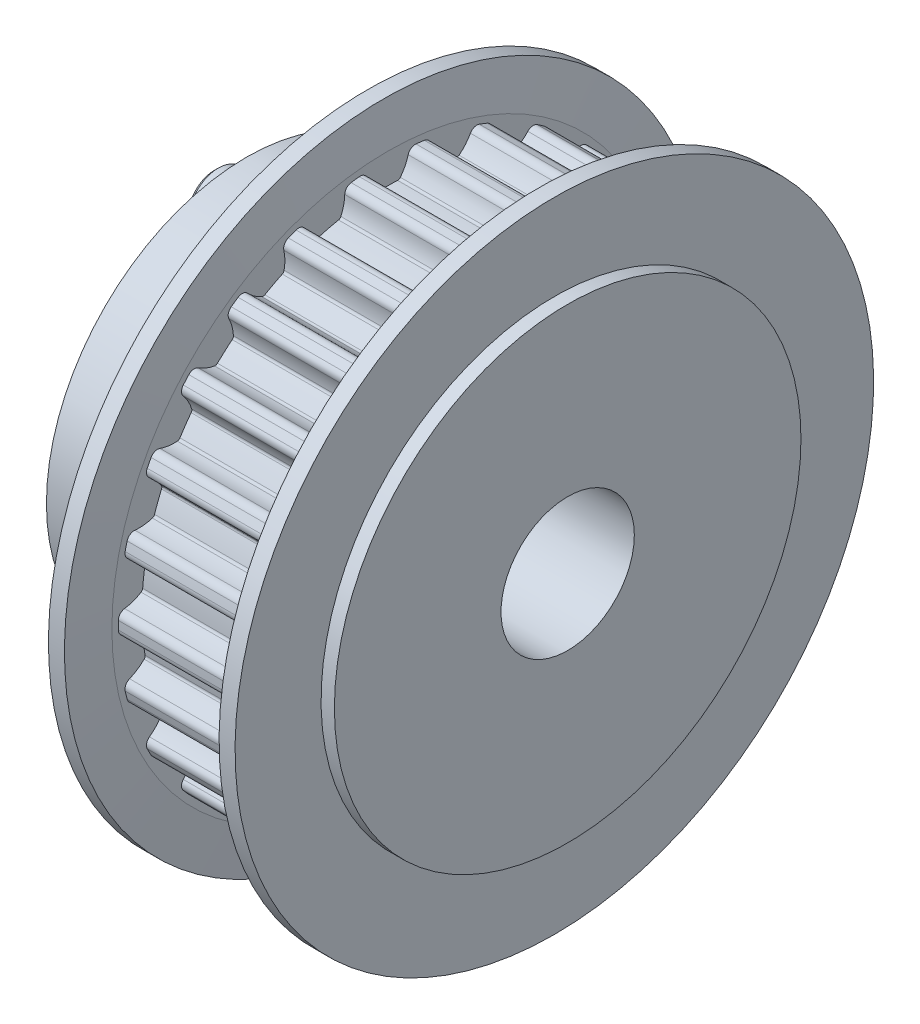
from build123d import *

# Parameters (mm, degrees)
CUT_EXTRUDE_1_DEPTH              = 14.5
FILLET_1_R                       = 0.55
FILLET_2_R                       = 0.25
PATTERN_CIRCULAR_1_COUNT         = 26
FILLET_1_OF_PATTERN_CIRCULAR_1_R = 0.55
FILLET_2_OF_PATTERN_CIRCULAR_1_R = 0.25
CUT_EXTRUDE_5_DEPTH              = 0.9
PATTERN_CIRCULAR_5_COUNT         = 3
SKETCH_14_R                      = 1.29
CUT_EXTRUDE_6_DEPTH              = 6.1
PATTERN_CIRCULAR_6_COUNT         = 3
SKETCH_15_R                      = 5
CUT_EXTRUDE_7_DEPTH              = 27.5


with BuildPart() as part:
    # 草图1 → 旋转1 (revolve)
    with BuildSketch(Plane.XY):
        Polygon((-8, 0), (-8, 17.5), (-5.5, 17.5), (-5.5, 20.21), (5.5, 20.21), (5.5, 17.5), (8, 17.5), (8, 0), align=None)
    revolve(axis=Axis((8, 0, 0), (-1, 0, 0)))

    # 草图2 → 切除-拉伸1 (cut, through all)
    with BuildSketch(Plane.ZY.offset(5.5)):
        with BuildLine():
            ThreePointArc((0.863830585, 18.41975561), (0, 18.44), (-0.863830585, 18.41975561))
            ThreePointArc((-0.863830585, 18.41975561), (-1.371211853, 19.226203854), (-1.625, 20.144564403))
            ThreePointArc((-1.625, 20.144564403), (0, 20.21), (1.625, 20.144564403))
            ThreePointArc((1.625, 20.144564403), (1.371211853, 19.226203854), (0.863830585, 18.41975561))
        make_face()
    cut_extrude_1 = extrude(amount=-CUT_EXTRUDE_1_DEPTH, mode=Mode.SUBTRACT)

    # 圆角1
    fillet_1_edges = [part.edges().sort_by_distance(p)[0] for p in [
        (0, 20.144564403, -1.625),
        (0, 20.144564403, 1.625),
    ]]
    fillet(fillet_1_edges, radius=FILLET_1_R)

    # 圆角2
    fillet_2_edges = [part.edges().sort_by_distance(p)[0] for p in [
        (0, 18.41975561, -0.863830585),
        (0, 18.41975561, 0.863830585),
    ]]
    fillet(fillet_2_edges, radius=FILLET_2_R)

    # 阵列(圆周)1: 切除-拉伸1 ×26 about axis
    pattern_circular_1_axis = Axis((0, 0, 0), (1, 0, 0))
    for i in range(1, PATTERN_CIRCULAR_1_COUNT):
        add(cut_extrude_1.rotate(pattern_circular_1_axis, i * 360 / PATTERN_CIRCULAR_1_COUNT), mode=Mode.SUBTRACT)

    # 圆角1 of 阵列(圆周)1
    fillet_1_of_pattern_circular_1_edges = [part.edges().sort_by_distance(p)[0] for p in [
        (0, 19.948087927, 3.243129359),
        (0, 19.170312019, 6.398690265),
        (0, 18.59230109, 7.922779827),
        (0, 17.081950781, 10.800511911),
        (0, 16.155997293, 12.14198713),
        (0, 14.000848653, 14.574647062),
        (0, 12.780765658, 15.655546276),
        (0, 10.106068094, 17.501756703),
        (0, 8.662762379, 18.259261977),
        (0, 5.62395959, 19.41172786),
        (0, 4.041310839, 19.801815743),
        (0, 0.815006998, 20.193559953),
        (0, -0.815006998, 20.193559953),
        (0, -4.041310839, 19.801815743),
        (0, -5.62395959, 19.41172786),
        (0, -8.662762379, 18.259261977),
        (0, -10.106068094, 17.501756703),
        (0, -12.780765658, 15.655546276),
        (0, -14.000848653, 14.574647062),
        (0, -16.155997293, 12.14198713),
        (0, -17.081950781, 10.800511911),
        (0, -18.59230109, 7.922779827),
        (0, -19.170312019, 6.398690265),
        (0, -19.948087927, 3.243129359),
        (0, -20.144564403, 1.625),
        (0, -20.144564403, -1.625),
        (0, -19.948087927, -3.243129359),
        (0, -19.170312019, -6.398690265),
        (0, -18.59230109, -7.922779827),
        (0, -17.081950781, -10.800511911),
        (0, -16.155997293, -12.14198713),
        (0, -14.000848653, -14.574647062),
        (0, -12.780765658, -15.655546276),
        (0, -10.106068094, -17.501756703),
        (0, -8.662762379, -18.259261977),
        (0, -5.62395959, -19.41172786),
        (0, -4.041310839, -19.801815743),
        (0, -0.815006998, -20.193559953),
        (0, 0.815006998, -20.193559953),
        (0, 4.041310839, -19.801815743),
        (0, 5.62395959, -19.41172786),
        (0, 8.662762379, -18.259261977),
        (0, 10.106068094, -17.501756703),
        (0, 12.780765658, -15.655546276),
        (0, 14.000848653, -14.574647062),
        (0, 16.155997293, -12.14198713),
        (0, 17.081950781, -10.800511911),
        (0, 18.59230109, -7.922779827),
        (0, 19.170312019, -6.398690265),
        (0, 19.948087927, -3.243129359),
    ]]
    fillet(fillet_1_of_pattern_circular_1_edges, radius=FILLET_1_OF_PATTERN_CIRCULAR_1_R)

    # 圆角2 of 阵列(圆周)1
    fillet_2_of_pattern_circular_1_edges = [part.edges().sort_by_distance(p)[0] for p in [
        (0, 18.091239179, 3.569406811),
        (0, 17.677782798, 5.246865288),
        (0, 16.711325685, 7.795203258),
        (0, 15.908441506, 9.324971252),
        (0, 14.360210687, 11.567970826),
        (0, 13.214559418, 12.861143782),
        (0, 11.17453244, 14.668449978),
        (0, 9.752695171, 15.649873383),
        (0, 7.339430986, 16.916452134),
        (0, 5.724039729, 17.529089229),
        (0, 3.07778848, 18.181331581),
        (0, 1.362723904, 18.389578124),
        (0, -1.362723904, 18.389578124),
        (0, -3.07778848, 18.181331581),
        (0, -5.724039729, 17.529089229),
        (0, -7.339430986, 16.916452134),
        (0, -9.752695171, 15.649873383),
        (0, -11.17453244, 14.668449978),
        (0, -13.214559418, 12.861143782),
        (0, -14.360210687, 11.567970826),
        (0, -15.908441506, 9.324971252),
        (0, -16.711325685, 7.795203258),
        (0, -17.677782798, 5.246865288),
        (0, -18.091239179, 3.569406811),
        (0, -18.41975561, 0.863830585),
        (0, -18.41975561, -0.863830585),
        (0, -18.091239179, -3.569406811),
        (0, -17.677782798, -5.246865288),
        (0, -16.711325685, -7.795203258),
        (0, -15.908441506, -9.324971252),
        (0, -14.360210687, -11.567970826),
        (0, -13.214559418, -12.861143782),
        (0, -11.17453244, -14.668449978),
        (0, -9.752695171, -15.649873383),
        (0, -7.339430986, -16.916452134),
        (0, -5.724039729, -17.529089229),
        (0, -3.07778848, -18.181331581),
        (0, -1.362723904, -18.389578124),
        (0, 1.362723904, -18.389578124),
        (0, 3.07778848, -18.181331581),
        (0, 5.724039729, -17.529089229),
        (0, 7.339430986, -16.916452134),
        (0, 9.752695171, -15.649873383),
        (0, 11.17453244, -14.668449978),
        (0, 13.214559418, -12.861143782),
        (0, 14.360210687, -11.567970826),
        (0, 15.908441506, -9.324971252),
        (0, 16.711325685, -7.795203258),
        (0, 17.677782798, -5.246865288),
        (0, 18.091239179, -3.569406811),
    ]]
    fillet(fillet_2_of_pattern_circular_1_edges, radius=FILLET_2_OF_PATTERN_CIRCULAR_1_R)

    # 草图3 → 旋转2 (revolve)
    with BuildSketch(Plane.XY):
        Polygon((-7, 17.5), (-7, 23.95), (-5.8, 23.95), (-5.5, 20.69), (-5.5, 17.5), align=None)
        Polygon((5.5, 20.69), (5.5, 17.5), (7, 17.5), (7, 23.95), (5.8, 23.95), align=None)
    revolve(axis=Axis((-8, 0, 0), (1, 0, 0)))

    # 草图11 → 旋转4 (revolve)
    with BuildSketch(Plane.XY):
        Polygon((-8, 5.5), (-10, 5.5), (-10, 15), (-16.1, 15), (-16.1, 0), (-8, 0), align=None)
    revolve(axis=Axis((-16.1, 0, 0), (1, 0, 0)))

    # 草图12 → 旋转5 (revolve)
    with BuildSketch(Plane.XY):
        Polygon((-18.2, 13.25), (-16.1, 13.25), (-16.1, 12.5), (-7, 12.5), (-7, 11), (-18.5, 11), (-18.5, 12.95), align=None)
    revolve_5 = revolve(axis=Axis((-7, 11, 0), (-1, 0, 0)))

    # 草图13 → 切除-拉伸5 (cut)
    with BuildSketch(Plane.ZY.offset(18.5)):
        Polygon((0, 12.489563695), (-1.29, 11.744781847), (-1.29, 10.255218153), (0, 9.510436305), (1.29, 10.255218153), (1.29, 11.744781847), align=None)
    cut_extrude_5 = extrude(amount=-CUT_EXTRUDE_5_DEPTH, mode=Mode.SUBTRACT)

    # 阵列(圆周)5: 旋转5, 切除-拉伸5 ×3 about axis
    pattern_circular_5_axis = Axis((0, 0, 0), (1, 0, 0))
    for i in range(1, PATTERN_CIRCULAR_5_COUNT):
        add(revolve_5.rotate(pattern_circular_5_axis, i * 360 / PATTERN_CIRCULAR_5_COUNT))
        add(cut_extrude_5.rotate(pattern_circular_5_axis, i * 360 / PATTERN_CIRCULAR_5_COUNT), mode=Mode.SUBTRACT)

    # 草图14 → 切除-拉伸6 (cut)
    with BuildSketch(Plane.ZY.offset(16.1)):
        with Locations((9.526279442, 5.5)):
            Circle(SKETCH_14_R)
    cut_extrude_6 = extrude(amount=-CUT_EXTRUDE_6_DEPTH, mode=Mode.SUBTRACT)

    # 阵列(圆周)6: 切除-拉伸6 ×3 about axis
    pattern_circular_6_axis = Axis((0, 0, 0), (1, 0, 0))
    for i in range(1, PATTERN_CIRCULAR_6_COUNT):
        add(cut_extrude_6.rotate(pattern_circular_6_axis, i * 360 / PATTERN_CIRCULAR_6_COUNT), mode=Mode.SUBTRACT)

    # 草图15 → 切除-拉伸7 (cut, through all)
    with BuildSketch(Plane(origin=(8, 0, 0), x_dir=(0, 0, -1), z_dir=(1, 0, 0))):
        Circle(SKETCH_15_R)
    extrude(amount=-CUT_EXTRUDE_7_DEPTH, mode=Mode.SUBTRACT)


solid = part.part
